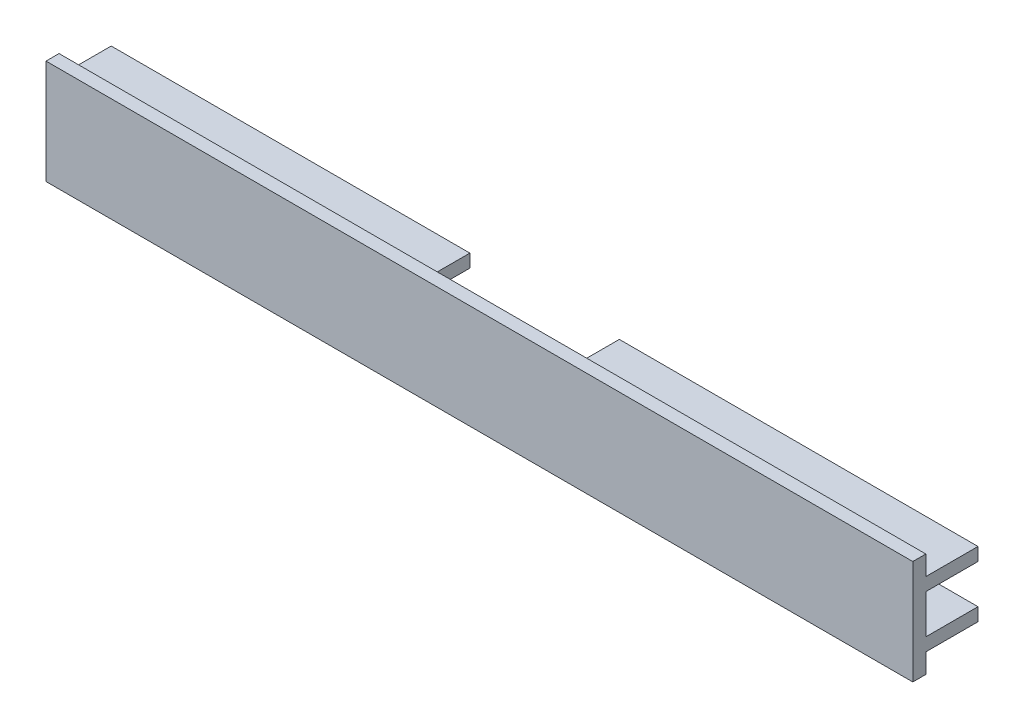
from build123d import *

# Parameters (mm, degrees)
EXTRUDE1_DEPTH = 66.46
SKETCH2_W      = 1
SKETCH2_H      = 6
EXTRUDE2_DEPTH = 56.5
SKETCH3_W      = 1
SKETCH3_H      = 6
EXTRUDE3_DEPTH = 56.5
EXTRUDE4_DEPTH = 1
SKETCH5_W      = 22.92
SKETCH5_H      = 10
EXTRUDE5_DEPTH = 7


with BuildPart() as part:
    # Sketch1 → Extrude1 (new body, symmetric)
    with BuildSketch(Plane(origin=(0, 0, 0), x_dir=(0, 0, -1), z_dir=(1, 0, 0))):
        Polygon((-3, 8), (-3, 5), (5, 5), (5, 3), (-2, 3), (-2, -3), (5, -3), (5, -5), (-3, -5), (-3, -8), (-5, -8), (-5, 8), align=None)
    extrude(amount=EXTRUDE1_DEPTH, both=True)

    # Sketch2 → Extrude2 (cut)
    with BuildSketch(Plane.ZY.offset(66.46)):
        with Locations((2.5, 0)):
            Rectangle(SKETCH2_W, SKETCH2_H)
    extrude(amount=-EXTRUDE2_DEPTH, mode=Mode.SUBTRACT)

    # Sketch3 → Extrude3 (cut)
    with BuildSketch(Plane(origin=(66.46, 0, 0), x_dir=(0, 0, -1), z_dir=(1, 0, 0))):
        with Locations((-2.5, 0)):
            Rectangle(SKETCH3_W, SKETCH3_H)
    extrude(amount=-EXTRUDE3_DEPTH, mode=Mode.SUBTRACT)

    # Sketch4 → Extrude4 (cut)
    with BuildSketch(Plane(origin=(0, 0, 2), x_dir=(-1, 0, 0), z_dir=(0, 0, -1))):
        with BuildLine():
            Line((-9.96, 3), (-9.96, -3))
            ThreePointArc((-9.96, -3), (-6.96, 0), (-9.96, 3))
        make_face()
        with BuildLine():
            Line((9.96, 3), (9.96, -3))
            ThreePointArc((9.96, -3), (6.96, 0), (9.96, 3))
        make_face()
    extrude(amount=-EXTRUDE4_DEPTH, mode=Mode.SUBTRACT)

    # Sketch5 → Extrude5 (cut)
    with BuildSketch(Plane(origin=(0, 0, -5), x_dir=(-1, 0, 0), z_dir=(0, 0, -1))):
        Rectangle(SKETCH5_W, SKETCH5_H)
    extrude(amount=-EXTRUDE5_DEPTH, mode=Mode.SUBTRACT)


solid = part.part
